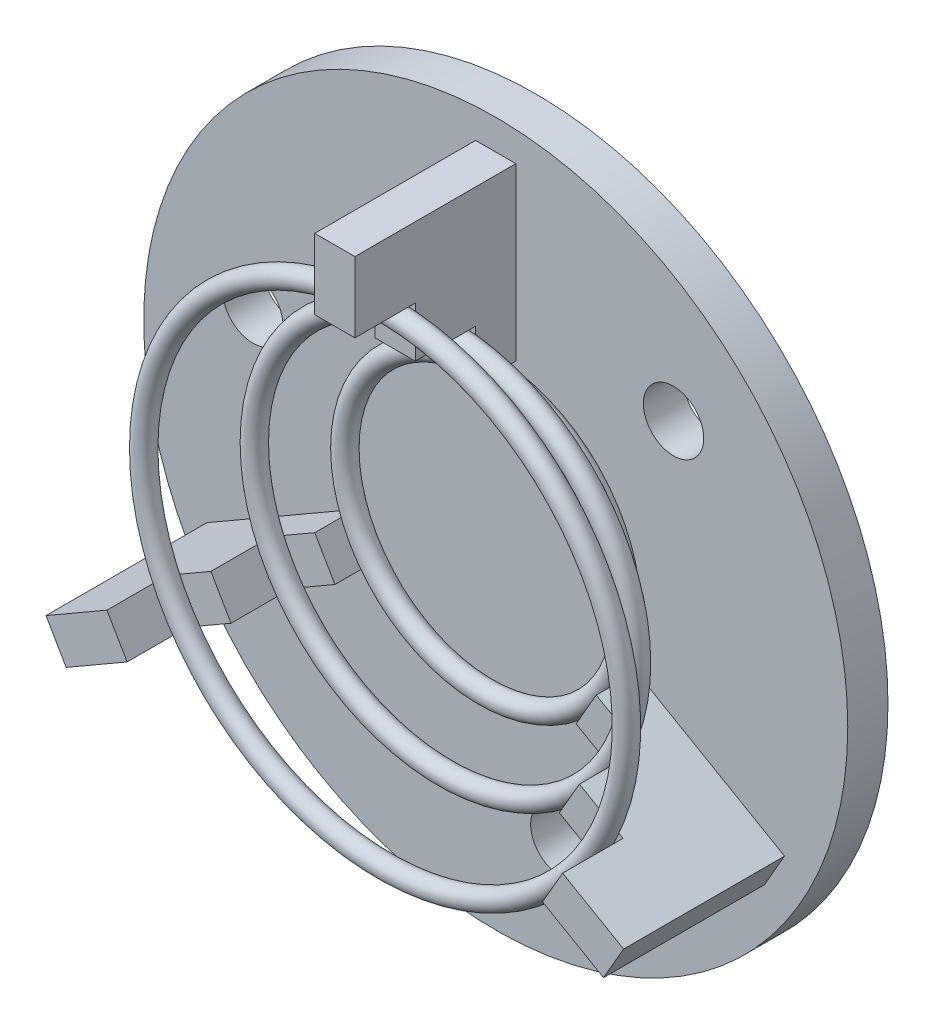
from build123d import *

# Parameters (mm, degrees)
SKETCH_1_R                 = 17.5
EXTRUDE_1_DEPTH            = 2
EXTRUDE_2_DEPTH            = 10
CUT_EXTRUDE_10_DEPTH       = 6
SKETCH_16_W                = 2
SKETCH_16_H                = 2.5
CUT_EXTRUDE_12_DEPTH       = 3
SKETCH_18_R                = 0.5
SKETCH_20_R                = 0.5
SKETCH_22_R                = 0.5
PATTERN_CIRCULAR_7_COUNT   = 3
PATTERN_CIRCULAR_7_2_COUNT = 3
SKETCH_24_R                = 1.5
CUT_EXTRUDE_16_DEPTH       = 5


with BuildPart() as part:
    # 草图1 → 凸台-拉伸1 (new body)
    with BuildSketch(Plane.XY):
        Circle(SKETCH_1_R)
    extrude(amount=EXTRUDE_1_DEPTH)

    # 草图2 → 凸台-拉伸2 (add)
    with BuildSketch(Plane.XY):
        Polygon((0, 7.5), (1, 7.5), (1, 16), (-1, 16), (-1, 7.5), align=None)
    extrude_2 = extrude(amount=EXTRUDE_2_DEPTH)

    # 草图3 → 切除-拉伸10 (cut)
    with BuildSketch(Plane.XY.offset(10)):
        Polygon((1, 7.5), (1, 10), (-1, 10), (-1, 8.75), (-1, 7.5), align=None)
    cut_extrude_10 = extrude(amount=-CUT_EXTRUDE_10_DEPTH, mode=Mode.SUBTRACT)

    # 草图16 → 切除-拉伸12 (cut)
    with BuildSketch(Plane.XY.offset(10)):
        with Locations((0, 11.25)):
            Rectangle(SKETCH_16_W, SKETCH_16_H)
    cut_extrude_12 = extrude(amount=-CUT_EXTRUDE_12_DEPTH, mode=Mode.SUBTRACT)

    # 阵列(圆周)7: 凸台-拉伸2 ×3 about axis
    pattern_circular_7_axis = Axis((0, 0, 2), (0, 0, -1))
    for i in range(1, PATTERN_CIRCULAR_7_COUNT):
        add(extrude_2.rotate(pattern_circular_7_axis, i * 360 / PATTERN_CIRCULAR_7_COUNT))

    # Pattern Circular 7 2: 切除-拉伸10, 切除-拉伸12 ×3 about axis
    pattern_circular_7_2_axis = Axis((0, 0, 2), (0, 0, -1))
    add([cut_extrude_10.rotate(pattern_circular_7_2_axis, i * 360 / PATTERN_CIRCULAR_7_2_COUNT) for i in range(1, PATTERN_CIRCULAR_7_2_COUNT)], mode=Mode.SUBTRACT)
    add([cut_extrude_12.rotate(pattern_circular_7_2_axis, i * 360 / PATTERN_CIRCULAR_7_2_COUNT) for i in range(1, PATTERN_CIRCULAR_7_2_COUNT)], mode=Mode.SUBTRACT)

    # 草图24 → 切除-拉伸16 (cut)
    with BuildSketch(Plane.XY.offset(4.5)):
        with Locations((3.235238064, -12.074072829)):
            Circle(SKETCH_24_R)
        with Locations((8.838834765, 8.838834765)):
            Circle(SKETCH_24_R)
        with Locations((-12.074072829, 3.235238064)):
            Circle(SKETCH_24_R)
    extrude(amount=-CUT_EXTRUDE_16_DEPTH, mode=Mode.SUBTRACT)


with BuildPart() as body_2:
    # 扫描3: sweep along a path in 草图17
    with BuildLine(Plane.XY.offset(2.5)) as sweep_3_path:
        CenterArc((0, 0), 7, 0, 360)
    # 草图18 → 扫描3 (sweep)
    with BuildSketch(Plane(origin=(0, 0, 0), x_dir=(1, 0, 0), z_dir=(0, 1, 0))):
        with Locations((-7, -2.5)):
            Circle(SKETCH_18_R)
    sweep(path=sweep_3_path.line)


with BuildPart() as body_3:
    # 扫描4: sweep along a path in 草图19
    with BuildLine(Plane.XY.offset(4.5)) as sweep_4_path:
        CenterArc((0, 0), 9.5, 0, 360)
    # 草图20 → 扫描4 (sweep)
    with BuildSketch(Plane(origin=(0, 0, 0), x_dir=(1, 0, 0), z_dir=(0, 1, 0))):
        with Locations((-9.5, -4.5)):
            Circle(SKETCH_20_R)
    sweep(path=sweep_4_path.line)


with BuildPart() as body_4:
    # 扫描5: sweep along a path in 草图21
    with BuildLine(Plane.XY.offset(7.5)) as sweep_5_path:
        CenterArc((0, 0), 12, 0, 360)
    # 草图22 → 扫描5 (sweep)
    with BuildSketch(Plane(origin=(0, 0, 0), x_dir=(1, 0, 0), z_dir=(0, 1, 0))):
        with Locations((-12, -7.5)):
            Circle(SKETCH_22_R)
    sweep(path=sweep_5_path.line)


solid = Compound([part.part, body_2.part, body_3.part, body_4.part])
